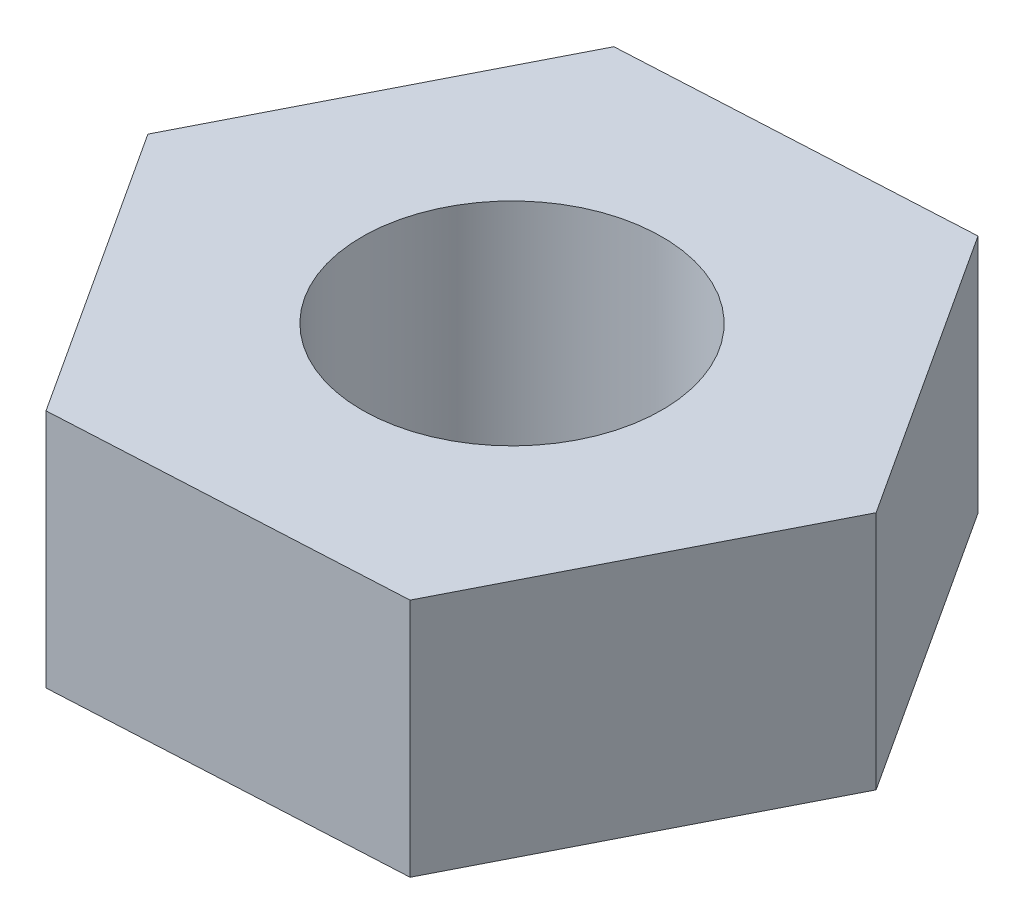
from build123d import *

# Parameters (mm, degrees)
SKETCH_1_R      = 1
EXTRUDE_1_DEPTH = 1.6


with BuildPart() as part:
    # 草图1 → 凸台-拉伸1 (new body)
    with BuildSketch(Plane(origin=(0, 0, 0), x_dir=(1, 0, 0), z_dir=(0, 1, 0))):
        Polygon((1.257712396, -1.93687709), (2.306240962, 0.120772341), (1.048528566, 2.057649431), (-1.257712396, 1.93687709), (-2.306240962, -0.120772341), (-1.048528566, -2.057649431), align=None)
        Circle(SKETCH_1_R, mode=Mode.SUBTRACT)
    extrude(amount=EXTRUDE_1_DEPTH)


solid = part.part
